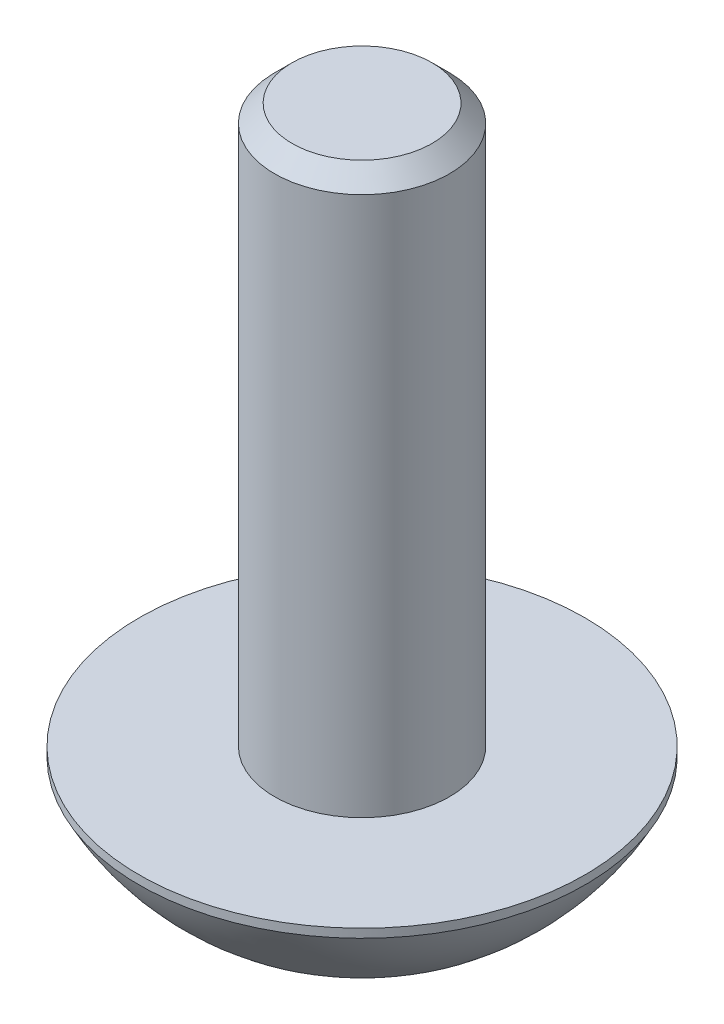
from build123d import *

# Parameters (mm, degrees)
SCHNITT_LINEAR_AUSTRAGEN1_DEPTH = 1.4375


with BuildPart() as part:
    # Skizze1 → Basis-Rotation (revolve)
    with BuildSketch(Plane.XY, mode=Mode.PRIVATE) as basis_rotation_sk:
        with BuildLine():
            Line((0, 12.3), (1.2564, 12.3))
            Line((1.2564, 12.3), (1.5705, 11.9859))
            Line((1.5705, 11.9859), (1.5705, 2.3))
            Line((1.5705, 2.3), (4, 2.3))
            Line((4, 2.3), (4, 2.14295))
            ThreePointArc((4, 2.14295), (2.998207899, 0.849769468), (1.600425673, 0))
            Line((1.600425673, 0), (1.443375673, 0))
            Line((1.443375673, 0), (1.2375, 0.205875673))
            Line((1.2375, 0.205875673), (1.2375, 1.4375))
            Line((1.2375, 1.4375), (0, 2.181065016))
            Line((0, 2.181065016), (0, 12.3))
        make_face()
    revolve(basis_rotation_sk.sketch.rotate(Axis((0, 0, 0), (0, 1, 0)), 90), axis=Axis((0, 0, 0), (0, 1, 0)))  # turned: the seam where the file's is

    # Skizze2 → Schnitt-Linear austragen1 (cut)
    with BuildSketch(Plane(origin=(0, 0, 0), x_dir=(1, 0, 0), z_dir=(0, 1, 0))):
        Polygon((-0.721687836, -1.25), (0.721687836, -1.25), (1.443375673, 0), (0.721687836, 1.25), (-0.721687836, 1.25), (-1.443375673, 0), align=None)
    extrude(amount=SCHNITT_LINEAR_AUSTRAGEN1_DEPTH, mode=Mode.SUBTRACT)


solid = part.part
